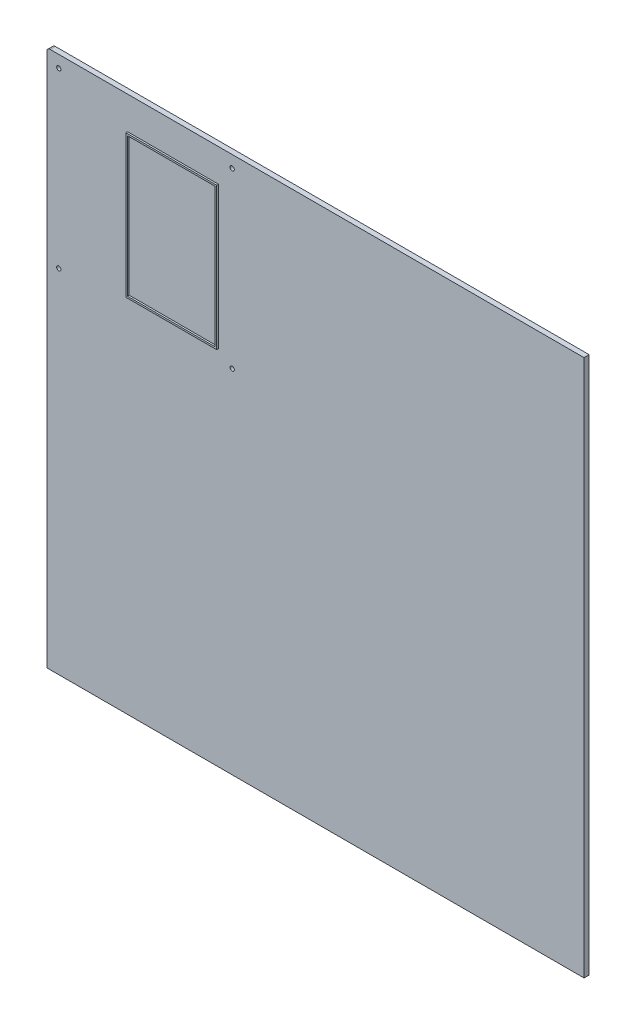
from build123d import *

# Parameters (mm, degrees)
ESQUISSE1_W        = 230
ESQUISSE1_H        = 230
ESQUISSE1_R        = 2.5
BOSS_EXTRU_1_DEPTH = 6
CONG_1_R           = 4
ESQUISSE2_W        = 106
ESQUISSE2_H        = 166
ESQUISSE2_W_2      = 102
ESQUISSE2_H_2      = 162
BOSS_EXTRU_2_DEPTH = 2
BOSS_EXTRU_3_DEPTH = 6


with BuildPart() as part:
    # Esquisse1 → Boss.-Extru.1 (new body)
    with BuildSketch(Plane.XY):
        with Locations((-28.150579015, -3.53164557)):
            Rectangle(ESQUISSE1_W, ESQUISSE1_H)
        with Locations((-129.150579015, 97.46835443)):
            Circle(ESQUISSE1_R, mode=Mode.SUBTRACT)
        with Locations((72.849420985, 97.46835443)):
            Circle(ESQUISSE1_R, mode=Mode.SUBTRACT)
        with Locations((72.849420985, -104.53164557)):
            Circle(ESQUISSE1_R, mode=Mode.SUBTRACT)
        with Locations((-129.150579015, -104.53164557)):
            Circle(ESQUISSE1_R, mode=Mode.SUBTRACT)
    extrude(amount=BOSS_EXTRU_1_DEPTH)

    # Congé1
    cong_1_edges = [part.edges().sort_by_distance(p)[0] for p in [
        (-143.150579015, 111.46835443, 3),
        (86.849420985, 111.46835443, 3),
        (86.849420985, -118.53164557, 3),
        (-143.150579015, -118.53164557, 3),
    ]]
    fillet(cong_1_edges, radius=CONG_1_R)

    # Esquisse2 → Boss.-Extru.2 (add)
    with BuildSketch(Plane.XY.offset(6)):
        with Locations((3.849420985, -9.53164557)):
            Rectangle(ESQUISSE2_W, ESQUISSE2_H)
        with Locations((3.849420985, -9.53164557)):
            Rectangle(ESQUISSE2_W_2, ESQUISSE2_H_2, mode=Mode.SUBTRACT)
    extrude(amount=BOSS_EXTRU_2_DEPTH)

    # Esquisse3 → Boss.-Extru.3 (add)
    with BuildSketch(Plane(origin=(0, 0, 0), x_dir=(-1, 0, 0), z_dir=(0, 0, -1))):
        Polygon((-82.849420985, 111.46835443), (-482.849420985, 111.46835443), (-482.849420985, -514.53164557), (143.150579015, -514.53164557), (143.150579015, -114.53164557), (-82.849420985, -114.53164557), align=None)
    extrude(amount=-BOSS_EXTRU_3_DEPTH)


solid = part.part
